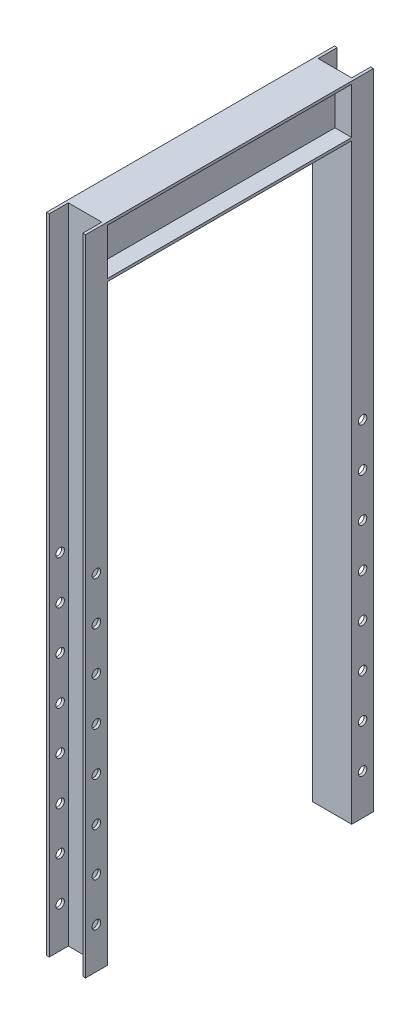
from build123d import *

# Parameters (mm, degrees)
BOSS_EXTRUDE1_DEPTH     = 285.75
BOSS_EXTRUDE2_DEPTH     = 1504.95
SKETCH4_R               = 10.033
CUT_EXTRUDE1_DEPTH      = 1428.530782148
LPATTERN1_COUNT         = 8
LPATTERN1_PITCH         = 101.6
MIRROR2_COPY_1_SKETCH_R = 10.033
MIRROR2_COPY_1_DEPTH    = 1428.530782148
MIRROR2_COPY_2_SKETCH_R = 10.033
MIRROR2_COPY_2_DEPTH    = 1428.530782148
MIRROR2_COPY_3_SKETCH_R = 10.033
MIRROR2_COPY_3_DEPTH    = 1428.530782148
MIRROR2_COPY_4_SKETCH_R = 10.033
MIRROR2_COPY_4_DEPTH    = 1428.530782148
MIRROR2_COPY_5_SKETCH_R = 10.033
MIRROR2_COPY_5_DEPTH    = 1428.530782148
MIRROR2_COPY_6_SKETCH_R = 10.033
MIRROR2_COPY_6_DEPTH    = 1428.530782148
MIRROR2_COPY_7_SKETCH_R = 10.033
MIRROR2_COPY_7_DEPTH    = 1428.530782148


with BuildPart() as part:
    # Sketch1 → Boss-Extrude1 (new, symmetric)
    with BuildSketch(Plane.XY):
        Polygon((45.5295, 120.65), (45.5295, 114.3), (6.35, 114.3), (6.35, 6.35), (45.5295, 6.35), (45.5295, 0), (0, 0), (0, 120.65), align=None)
    boss_extrude1 = extrude(amount=BOSS_EXTRUDE1_DEPTH, both=True)

    # Mirror1: Boss-Extrude1 across plane
    add(boss_extrude1.mirror(Plane(origin=(0, 120.65, 285.75), x_dir=(0, 0, 1), z_dir=(1, 0, 0))))

    # Sketch3 → Boss-Extrude2 (add)
    with BuildSketch(Plane(origin=(0, 120.65, 0), x_dir=(1, 0, 0), z_dir=(0, 1, 0))):
        Polygon((-45.5295, -285.75), (45.5295, -285.75), (45.5295, -336.55), (39.1795, -336.55), (39.1795, -292.1), (-39.1795, -292.1), (-39.1795, -336.55), (-45.5295, -336.55), align=None)
    boss_extrude2 = extrude(amount=-BOSS_EXTRUDE2_DEPTH)

    # Sketch4 → Cut-Extrude1 (cut, through all)
    with BuildSketch(Plane(origin=(45.5295, 0, 0), x_dir=(0, 0, -1), z_dir=(1, 0, 0))):
        with Locations((-311.15, -577.85)):
            Circle(SKETCH4_R)
    cut_extrude1 = extrude(amount=-CUT_EXTRUDE1_DEPTH, mode=Mode.SUBTRACT)

    # LPattern1: Cut-Extrude1 ×8
    with Locations(*[(0, -i * LPATTERN1_PITCH, 0) for i in range(1, LPATTERN1_COUNT)]):
        add(cut_extrude1, mode=Mode.SUBTRACT)

    # Mirror2: Boss-Extrude2, Cut-Extrude1 across plane
    add(boss_extrude2.mirror(Plane.XY))
    add(cut_extrude1.mirror(Plane.XY), mode=Mode.SUBTRACT)

    # Mirror2 copy 1 sketch → Mirror2 copy 1 (cut, through all)
    with BuildSketch(Plane(origin=(45.5295, -101.6, 0), x_dir=(0, 0, 1), z_dir=(1, 0, 0))):
        with Locations((-311.15, 577.85)):
            Circle(MIRROR2_COPY_1_SKETCH_R)
    extrude(amount=-MIRROR2_COPY_1_DEPTH, mode=Mode.SUBTRACT)

    # Mirror2 copy 2 sketch → Mirror2 copy 2 (cut, through all)
    with BuildSketch(Plane(origin=(45.5295, -203.2, 0), x_dir=(0, 0, 1), z_dir=(1, 0, 0))):
        with Locations((-311.15, 577.85)):
            Circle(MIRROR2_COPY_2_SKETCH_R)
    extrude(amount=-MIRROR2_COPY_2_DEPTH, mode=Mode.SUBTRACT)

    # Mirror2 copy 3 sketch → Mirror2 copy 3 (cut, through all)
    with BuildSketch(Plane(origin=(45.5295, -304.8, 0), x_dir=(0, 0, 1), z_dir=(1, 0, 0))):
        with Locations((-311.15, 577.85)):
            Circle(MIRROR2_COPY_3_SKETCH_R)
    extrude(amount=-MIRROR2_COPY_3_DEPTH, mode=Mode.SUBTRACT)

    # Mirror2 copy 4 sketch → Mirror2 copy 4 (cut, through all)
    with BuildSketch(Plane(origin=(45.5295, -406.4, 0), x_dir=(0, 0, 1), z_dir=(1, 0, 0))):
        with Locations((-311.15, 577.85)):
            Circle(MIRROR2_COPY_4_SKETCH_R)
    extrude(amount=-MIRROR2_COPY_4_DEPTH, mode=Mode.SUBTRACT)

    # Mirror2 copy 5 sketch → Mirror2 copy 5 (cut, through all)
    with BuildSketch(Plane(origin=(45.5295, -508, 0), x_dir=(0, 0, 1), z_dir=(1, 0, 0))):
        with Locations((-311.15, 577.85)):
            Circle(MIRROR2_COPY_5_SKETCH_R)
    extrude(amount=-MIRROR2_COPY_5_DEPTH, mode=Mode.SUBTRACT)

    # Mirror2 copy 6 sketch → Mirror2 copy 6 (cut, through all)
    with BuildSketch(Plane(origin=(45.5295, -609.6, 0), x_dir=(0, 0, 1), z_dir=(1, 0, 0))):
        with Locations((-311.15, 577.85)):
            Circle(MIRROR2_COPY_6_SKETCH_R)
    extrude(amount=-MIRROR2_COPY_6_DEPTH, mode=Mode.SUBTRACT)

    # Mirror2 copy 7 sketch → Mirror2 copy 7 (cut, through all)
    with BuildSketch(Plane(origin=(45.5295, -711.2, 0), x_dir=(0, 0, 1), z_dir=(1, 0, 0))):
        with Locations((-311.15, 577.85)):
            Circle(MIRROR2_COPY_7_SKETCH_R)
    extrude(amount=-MIRROR2_COPY_7_DEPTH, mode=Mode.SUBTRACT)


solid = part.part
